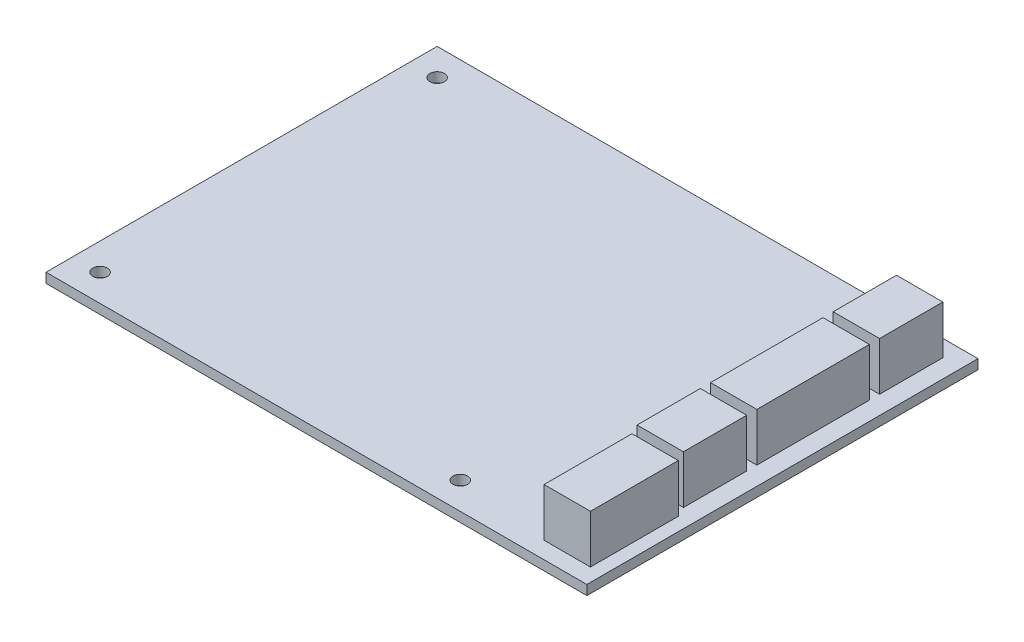
from build123d import *

# Parameters (mm, degrees)
ESQUISSE1_W             = 112
ESQUISSE1_H             = 81
BOSS_EXTRU_1_DEPTH      = 2
ESQUISSE2_R             = 1.5
ENL_V_MAT_EXTRU_1_DEPTH = 10
ESQUISSE3_W             = 9.6
ESQUISSE3_H             = 13.1
ESQUISSE3_H_2           = 23.3
ESQUISSE3_H_3           = 18.2
BOSS_EXTRU_2_DEPTH      = 10


with BuildPart() as part:
    # Esquisse1 → Boss.-Extru.1 (new body)
    with BuildSketch(Plane(origin=(0, 0, 0), x_dir=(1, 0, 0), z_dir=(0, 1, 0))):
        Rectangle(ESQUISSE1_W, ESQUISSE1_H)
    extrude(amount=BOSS_EXTRU_1_DEPTH)

    # Esquisse2 → Enlèv. mat.-Extru.1 (cut)
    with BuildSketch(Plane(origin=(0, 2, 0), x_dir=(1, 0, 0), z_dir=(0, 1, 0))):
        with Locations((-50.4, 34.9)):
            Circle(ESQUISSE2_R)
        with Locations((-50.4, -34.9)):
            Circle(ESQUISSE2_R)
        with Locations((24.2, -34.9)):
            Circle(ESQUISSE2_R)
        with Locations((37.7, 18.1)):
            Circle(ESQUISSE2_R)
    extrude(amount=-ENL_V_MAT_EXTRU_1_DEPTH, mode=Mode.SUBTRACT)

    # Esquisse3 → Boss.-Extru.2 (add)
    with BuildSketch(Plane(origin=(0, 2, -2), x_dir=(1, 0, 0), z_dir=(0, -1, 0))):
        with Locations((47.4, 12.15)):
            Rectangle(ESQUISSE3_W, ESQUISSE3_H)
        with Locations((47.4, -8.15)):
            Rectangle(ESQUISSE3_W, ESQUISSE3_H_2)
        with Locations((47.4, -28.47)):
            Rectangle(ESQUISSE3_W, ESQUISSE3_H)
        with Locations((48.442, 29.9)):
            Rectangle(ESQUISSE3_W, ESQUISSE3_H_3)
    extrude(amount=-BOSS_EXTRU_2_DEPTH)


solid = part.part
